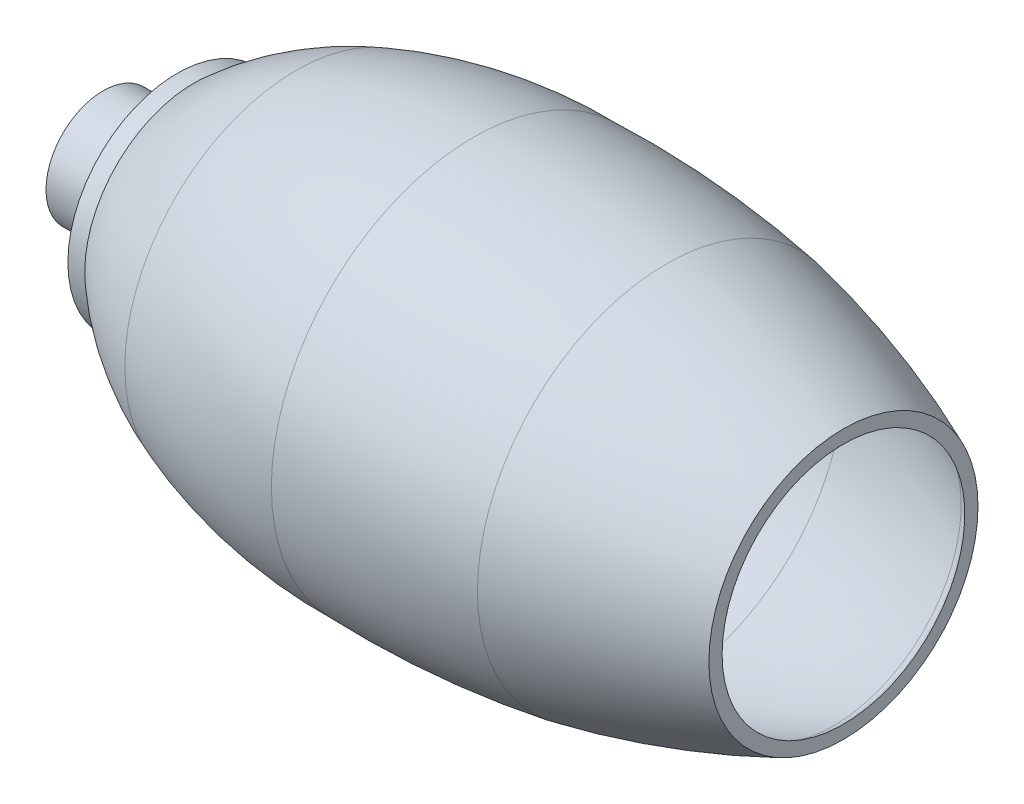
from build123d import *


with BuildPart() as part:
    # Sketch2 → Revolve2 (revolve)
    with BuildSketch(Plane.XY):
        with BuildLine():
            Line((0, 73.992963131), (13.638295153, 73.992963131))
            Line((13.638295153, 73.992963131), (23.633885542, 89.491737237))
            Line((23.633885542, 89.491737237), (28.165268574, 89.491737237))
            ThreePointArc((28.165268574, 89.491737237), (42.356771966, 100.253637016), (58.358984334, 108.073256874))
            ThreePointArc((58.358984334, 108.073256874), (83.772170346, 114.95166298), (110.019307059, 117.008434295))
            ThreePointArc((110.019307059, 117.008434295), (138.535641093, 116.50770952), (166.866357242, 113.220985542))
            ThreePointArc((166.866357242, 113.220985542), (192.309227067, 106.869033698), (216.988579084, 98.002439021))
            ThreePointArc((216.988579084, 98.002439021), (218.582918186, 97.181325857), (219.988579084, 96.067655601))
            Line((219.988579084, 96.067655601), (219.988579084, 99.993693578))
            ThreePointArc((219.988579084, 99.993693578), (194.116843001, 109.453535678), (167.402005562, 116.173119081))
            ThreePointArc((167.402005562, 116.173119081), (138.792106802, 119.497267879), (109.994289542, 120.009120724))
            ThreePointArc((109.994289542, 120.009120724), (83.226586613, 117.901836639), (57.309483773, 110.88369253))
            ThreePointArc((57.309483773, 110.88369253), (41.288666098, 103.116731205), (27.00224631, 92.491737237))
            Line((27.00224631, 92.491737237), (21.99888089, 92.491737237))
            Line((21.99888089, 92.491737237), (12.0032905, 76.992963131))
            Line((12.0032905, 76.992963131), (0, 76.992963131))
            Line((0, 76.992963131), (0, 73.992963131))
        make_face()
    revolve(axis=Axis((0, 60.004560362, 0), (1, 0, 0)))


solid = part.part
